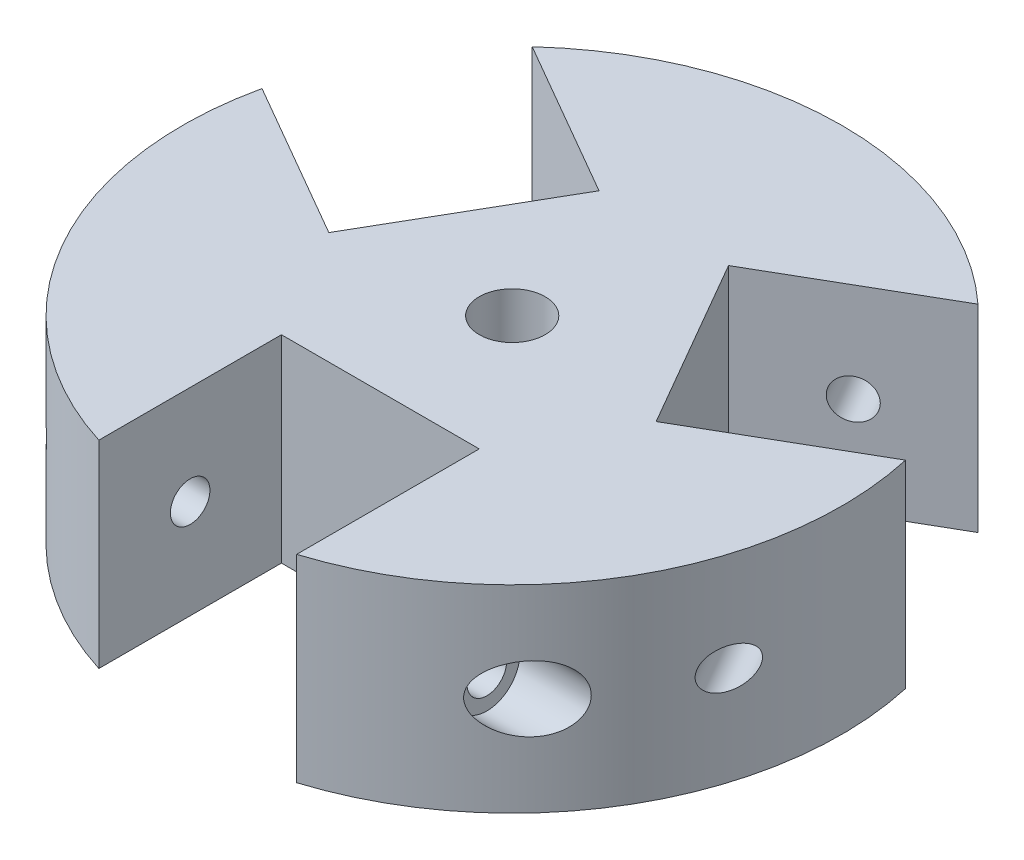
from build123d import *

# Parameters (mm, degrees)
SKETCH1_R           = 25
BOSS_EXTRUDE1_DEPTH = 15
CUT_EXTRUDE1_START  = -150
CUT_EXTRUDE1_DEPTH  = 150
SKETCH3_R           = 1.5
CUT_EXTRUDE2_DEPTH  = 44.660622991
CUT_EXTRUDE3_START  = -7.5
SKETCH4_R           = 2.5
CUT_EXTRUDE3_DEPTH  = 10
CIRPATTERN1_COUNT   = 3
SKETCH5_R           = 2.5
CUT_EXTRUDE4_DEPTH  = 39.405728909


with BuildPart() as part:
    # Sketch1 → Boss-Extrude1 (new body)
    with BuildSketch(Plane(origin=(0, 0, 0), x_dir=(1, 0, 0), z_dir=(0, 1, 0))):
        Circle(SKETCH1_R)
    extrude(amount=BOSS_EXTRUDE1_DEPTH)

    # Sketch2 → Cut-Extrude1 (cut)
    with BuildSketch(Plane(origin=(0, 15, 0), x_dir=(1, 0, 0), z_dir=(0, 1, 0)).offset(CUT_EXTRUDE1_START)):
        with BuildLine():
            Line((7.5, -10), (-7.5, -10))
            Line((-7.5, -10), (-7.5, -23.848480035))
            ThreePointArc((-7.5, -23.848480035), (0, -25), (7.5, -23.848480035))
            Line((7.5, -23.848480035), (7.5, -10))
        make_face()
    cut_extrude1 = extrude(amount=CUT_EXTRUDE1_DEPTH, mode=Mode.SUBTRACT)

    # Sketch3 → Cut-Extrude2 (cut, symmetric)
    with BuildSketch(Plane.ZY.offset(-7.5)):
        with Locations((16.924240018, 7.5)):
            Circle(SKETCH3_R)
    cut_extrude2 = extrude(amount=CUT_EXTRUDE2_DEPTH, both=True, mode=Mode.SUBTRACT)

    # Sketch4 → Cut-Extrude3 (cut)
    with BuildSketch(Plane.ZY.offset(-7.5).offset(CUT_EXTRUDE3_START)):
        with Locations((16.924240018, 7.5)):
            Circle(SKETCH4_R)
    cut_extrude3 = extrude(amount=-CUT_EXTRUDE3_DEPTH, mode=Mode.SUBTRACT)

    # CirPattern1: Cut-Extrude1, Cut-Extrude2, Cut-Extrude3 ×3 about axis
    cirpattern1_axis = Axis((0, 15, 0), (0, 1, 0))
    add([cut_extrude1.rotate(cirpattern1_axis, i * 360 / CIRPATTERN1_COUNT) for i in range(1, CIRPATTERN1_COUNT)], mode=Mode.SUBTRACT)
    add([cut_extrude2.rotate(cirpattern1_axis, i * 360 / CIRPATTERN1_COUNT) for i in range(1, CIRPATTERN1_COUNT)], mode=Mode.SUBTRACT)
    add([cut_extrude3.rotate(cirpattern1_axis, i * 360 / CIRPATTERN1_COUNT) for i in range(1, CIRPATTERN1_COUNT)], mode=Mode.SUBTRACT)

    # Sketch5 → Cut-Extrude4 (cut, through all)
    with BuildSketch(Plane(origin=(0, 15, 0), x_dir=(1, 0, 0), z_dir=(0, 1, 0))):
        Circle(SKETCH5_R)
    extrude(amount=-CUT_EXTRUDE4_DEPTH, mode=Mode.SUBTRACT)


solid = part.part
